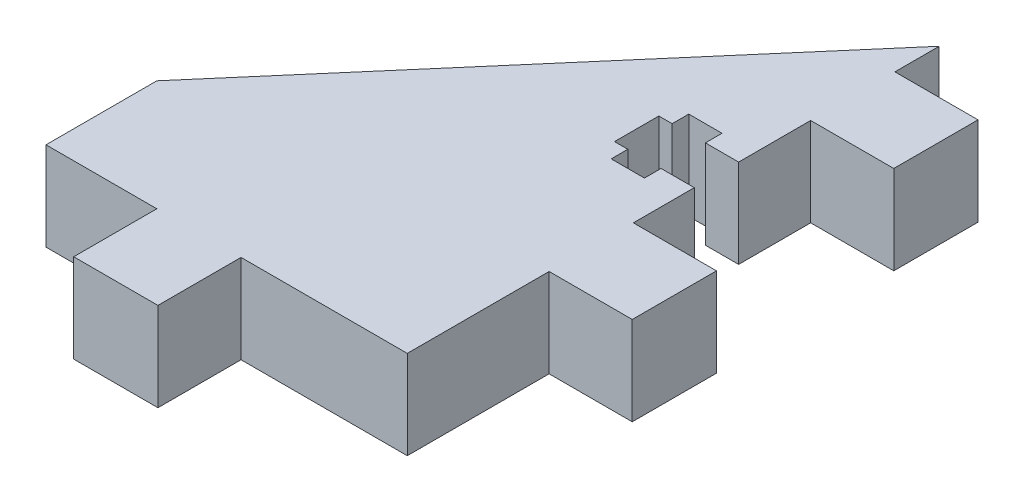
from build123d import *

# Parameters (mm, degrees)
BOSS_EXTRUDE1_DEPTH = 8


with BuildPart() as part:
    # Sketch1 → Boss-Extrude1 (new body)
    with BuildSketch(Plane(origin=(0, 0, 0), x_dir=(1, 0, 0), z_dir=(0, 1, 0))):
        Polygon((0, 0), (-15, 0), (-15, -7.5), (-22.6, -7.5), (-22.6, 0), (-32.6, 0), (-32.6, 10), (0, 48), (0, 44), (7.5, 44), (7.5, 36.4), (0, 36.4), (0, 29.9), (-3, 29.9), (-3, 31.4), (-6, 31.4), (-6, 29.9), (-7.2, 29.9), (-7.2, 25.9), (-6, 25.9), (-6, 24.4), (-3, 24.4), (-3, 25.9), (0, 25.9), (0, 20.4), (7.5, 20.4), (7.5, 12.8), (0, 12.8), align=None)
    extrude(amount=BOSS_EXTRUDE1_DEPTH)


solid = part.part
